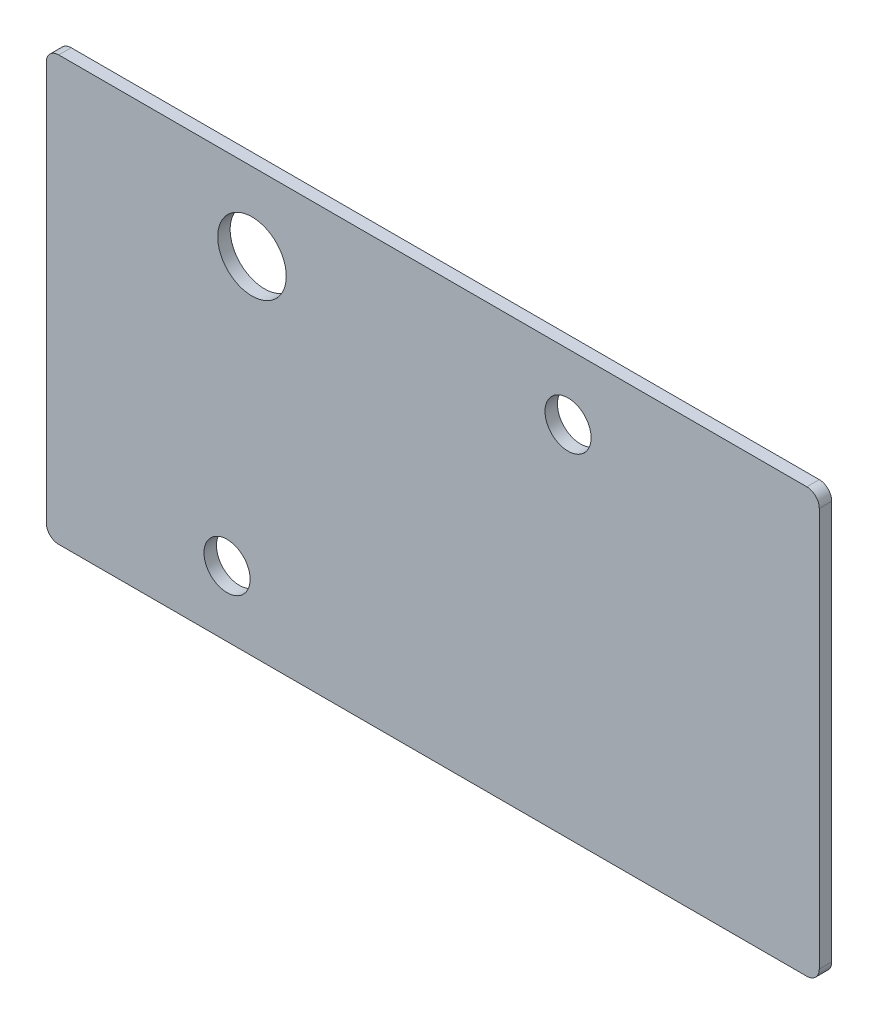
from build123d import *

# Parameters (mm, degrees)
CROQUIS1_R              = 1.85
SALIENTE_EXTRUIR1_DEPTH = 1
CROQUIS2_R              = 2.75
CORTAR_EXTRUIR1_DEPTH   = 2


with BuildPart() as part:
    # Croquis1 → Saliente-Extruir1 (new body)
    with BuildSketch(Plane.XY):
        with BuildLine():
            Line((-5, 31.75), (55, 31.75))
            ThreePointArc((55, 31.75), (55.707106781, 31.457106781), (56, 30.75))
            Line((56, 30.75), (56, -1.25))
            ThreePointArc((56, -1.25), (55.707106781, -1.957106781), (55, -2.25))
            Line((55, -2.25), (-5, -2.25))
            ThreePointArc((-5, -2.25), (-5.707106781, -1.957106781), (-6, -1.25))
            Line((-6, -1.25), (-6, 30.75))
            ThreePointArc((-6, 30.75), (-5.707106781, 31.457106781), (-5, 31.75))
        make_face()
        with Locations((35.85, 26.5)):
            Circle(CROQUIS1_R, mode=Mode.SUBTRACT)
        with Locations((8.5, 3)):
            Circle(CROQUIS1_R, mode=Mode.SUBTRACT)
    extrude(amount=SALIENTE_EXTRUIR1_DEPTH)

    # Croquis2 → Cortar-Extruir1 (cut, through all)
    with BuildSketch(Plane.XY.offset(1)):
        with Locations((10.5, 25.5)):
            Circle(CROQUIS2_R)
    extrude(amount=-CORTAR_EXTRUIR1_DEPTH, mode=Mode.SUBTRACT)


solid = part.part
